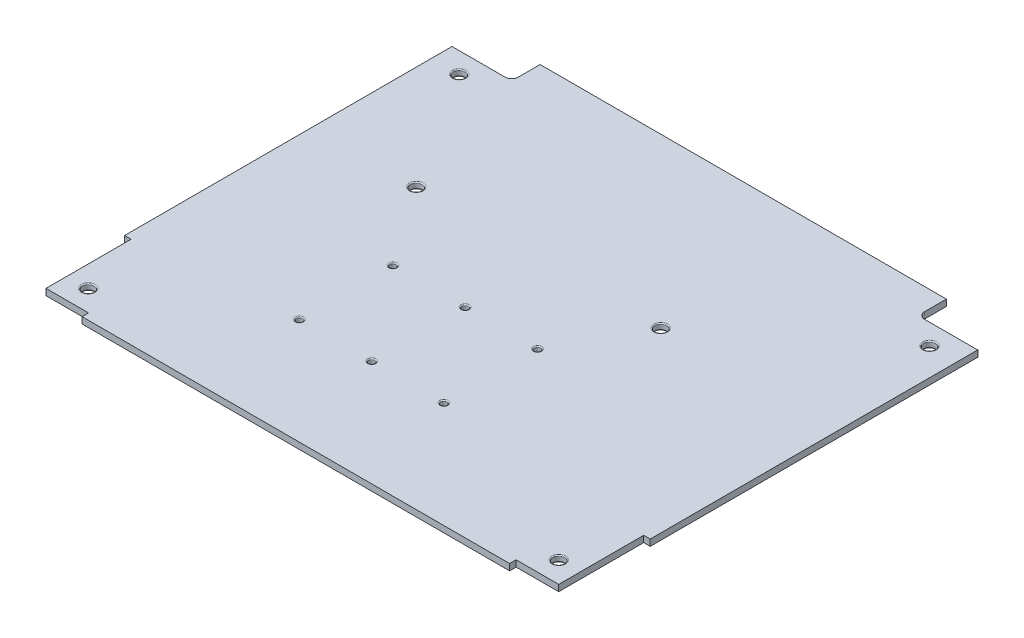
from build123d import *

# Parameters (mm, degrees)
SKETCH1_W           = 247.3
SKETCH1_H           = 210.475
BOSS_EXTRUDE1_DEPTH = 3
CUT_EXTRUDE2_DEPTH  = 4
SKETCH2_R           = 2.75
CUT_EXTRUDE1_DEPTH  = 4
FILLET1_R           = 0.5
SKETCH8_R           = 1.5
CUT_EXTRUDE6_DEPTH  = 4
FILLET2_R           = 0.5
SKETCH9_R           = 2.75
CUT_EXTRUDE7_DEPTH  = 4
FILLET3_R           = 0.5
CUT_EXTRUDE10_DEPTH = 4


with BuildPart() as part:
    # Sketch1 → Boss-Extrude1 (new body)
    with BuildSketch(Plane(origin=(0, 0, 0), x_dir=(1, 0, 0), z_dir=(0, 1, 0))):
        Rectangle(SKETCH1_W, SKETCH1_H)
    extrude(amount=BOSS_EXTRUDE1_DEPTH)

    # Sketch4 → Cut-Extrude2 (cut, through all)
    with BuildSketch(Plane(origin=(0, 3, 0), x_dir=(1, 0, 0), z_dir=(0, 1, 0))):
        Polygon((-123.65, -105.2375), (-120.6, -105.2375), (-100.6, -105.2375), (-100.6, -102.1875), (-120.6, -102.1875), (-120.6, -62.1875), (-123.65, -62.1875), align=None)
        Polygon((100.6, -105.2375), (100.6, -102.1875), (120.6, -102.1875), (120.6, -62.1875), (123.65, -62.1875), (123.65, -105.2375), (120.6, -105.2375), align=None)
    extrude(amount=-CUT_EXTRUDE2_DEPTH, mode=Mode.SUBTRACT)

    # Sketch2 → Cut-Extrude1 (cut, through all)
    with BuildSketch(Plane(origin=(0, 3, 0), x_dir=(1, 0, 0), z_dir=(0, 1, 0))):
        with Locations((-110.65, 82.2375)):
            Circle(SKETCH2_R)
        with Locations((110.65, 82.2375)):
            Circle(SKETCH2_R)
        with Locations((-110.65, -92.2375)):
            Circle(SKETCH2_R)
        with Locations((110.65, -92.2375)):
            Circle(SKETCH2_R)
    extrude(amount=-CUT_EXTRUDE1_DEPTH, mode=Mode.SUBTRACT)

    # Fillet1
    fillet1_edges = [part.edges().sort_by_distance(p)[0] for p in [
        (107.9, 0, -82.2375),
        (107.9, 3, -82.2375),
        (-113.4, 0, 92.2375),
        (-113.4, 3, 92.2375),
        (107.9, 0, 92.2375),
        (107.9, 3, 92.2375),
        (-113.4, 0, -82.2375),
        (-113.4, 3, -82.2375),
    ]]
    fillet(fillet1_edges, radius=FILLET1_R)

    # Sketch8 → Cut-Extrude6 (cut, through all)
    with BuildSketch(Plane(origin=(0, 3, 0), x_dir=(1, 0, 0), z_dir=(0, 1, 0))):
        with Locations((19.65, -55.2375)):
            Circle(SKETCH8_R)
        with Locations((-14.35, -55.2375)):
            Circle(SKETCH8_R)
        with Locations((-48.35, -55.2375)):
            Circle(SKETCH8_R)
        with Locations((-48.35, -11.2375)):
            Circle(SKETCH8_R)
        with Locations((-14.35, -11.2375)):
            Circle(SKETCH8_R)
        with Locations((19.65, -11.2375)):
            Circle(SKETCH8_R)
    extrude(amount=-CUT_EXTRUDE6_DEPTH, mode=Mode.SUBTRACT)

    # Fillet2
    fillet2_edges = [part.edges().sort_by_distance(p)[0] for p in [
        (18.15, 0, 11.2375),
        (18.15, 3, 11.2375),
        (-15.85, 0, 11.2375),
        (-15.85, 3, 11.2375),
        (-49.85, 0, 11.2375),
        (-49.85, 3, 11.2375),
        (-49.85, 0, 55.2375),
        (-49.85, 3, 55.2375),
        (-15.85, 0, 55.2375),
        (-15.85, 3, 55.2375),
        (18.15, 0, 55.2375),
        (18.15, 3, 55.2375),
    ]]
    fillet(fillet2_edges, radius=FILLET2_R)

    # Sketch9 → Cut-Extrude7 (cut, through all)
    with BuildSketch(Plane(origin=(0, 3, 0), x_dir=(1, 0, 0), z_dir=(0, 1, 0))):
        with Locations((-74.85, 26.2625)):
            Circle(SKETCH9_R)
        with Locations((40.15, 26.2625)):
            Circle(SKETCH9_R)
    extrude(amount=-CUT_EXTRUDE7_DEPTH, mode=Mode.SUBTRACT)

    # Fillet3
    fillet3_edges = [part.edges().sort_by_distance(p)[0] for p in [
        (-77.6, 0, -26.2625),
        (-77.6, 3, -26.2625),
        (37.4, 0, -26.2625),
        (37.4, 3, -26.2625),
    ]]
    fillet(fillet3_edges, radius=FILLET3_R)

    # Sketch12 → Cut-Extrude10 (cut, through all)
    with BuildSketch(Plane.XZ):
        with BuildLine():
            Line((125.725, -105.2375), (125.725, -94.9145))
            ThreePointArc((125.725, -94.9145), (124.831675683, -92.757824317), (122.675, -91.8645))
            Line((122.675, -91.8645), (98.625, -91.8645))
            ThreePointArc((98.625, -91.8645), (96.468324317, -92.757824317), (95.575, -94.9145))
            Line((95.575, -94.9145), (95.575, -105.2375))
            Line((95.575, -105.2375), (125.725, -105.2375))
        make_face()
        with BuildLine():
            Line((-95.575, -105.2375), (-125.725, -105.2375))
            Line((-125.725, -105.2375), (-125.725, -94.9145))
            ThreePointArc((-125.725, -94.9145), (-124.831675683, -92.757824317), (-122.675, -91.8645))
            Line((-122.675, -91.8645), (-98.625, -91.8645))
            ThreePointArc((-98.625, -91.8645), (-96.468324317, -92.757824317), (-95.575, -94.9145))
            Line((-95.575, -94.9145), (-95.575, -105.2375))
        make_face()
    extrude(amount=-CUT_EXTRUDE10_DEPTH, mode=Mode.SUBTRACT)


solid = part.part
